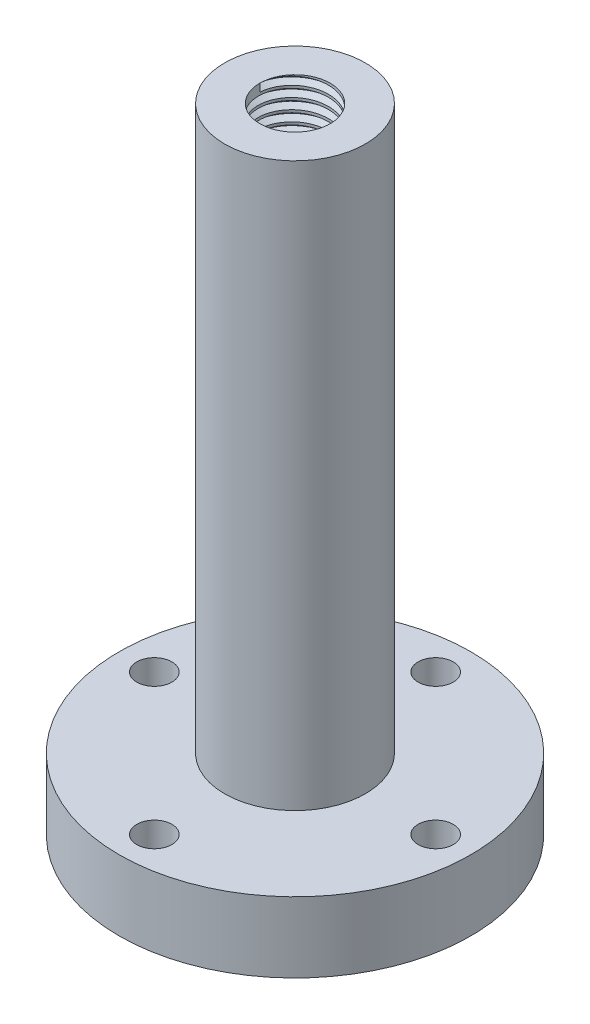
from build123d import *

# Parameters (mm, degrees)
SKETCH1_R           = 25
BOSS_EXTRUDE1_DEPTH = 10
SKETCH2_R           = 10
BOSS_EXTRUDE2_DEPTH = 80
SKETCH3_R           = 5
CUT_EXTRUDE1_DEPTH  = 97.695398029
THREAD1_PITCH       = 1.5
THREAD1_HEIGHT      = 10
THREAD1_RADIUS      = 5
THREAD1_START_ANGLE = -90
SKETCH6_R           = 2.5
CUT_EXTRUDE2_DEPTH  = 97.695398122


with BuildPart() as part:
    # Sketch1 → Boss-Extrude1 (new body)
    with BuildSketch(Plane(origin=(0, 0, 0), x_dir=(1, 0, 0), z_dir=(0, 1, 0))):
        with Locations(Location((0, 0, 0), (0, 0, 270))):
            Circle(SKETCH1_R)
    extrude(amount=BOSS_EXTRUDE1_DEPTH)

    # Sketch2 → Boss-Extrude2 (add)
    with BuildSketch(Plane(origin=(0, 10, 0), x_dir=(1, 0, 0), z_dir=(0, 1, 0))):
        with Locations(Location((0, 0, 0), (0, 0, 270))):
            Circle(SKETCH2_R)
    extrude(amount=BOSS_EXTRUDE2_DEPTH)

    # Sketch3 → Cut-Extrude1 (cut, through all)
    with BuildSketch(Plane(origin=(0, 90, 0), x_dir=(1, 0, 0), z_dir=(0, 1, 0))):
        with Locations(Location((0, 0, 0), (0, 0, 270))):
            Circle(SKETCH3_R)
    extrude(amount=-CUT_EXTRUDE1_DEPTH, mode=Mode.SUBTRACT)

    # Thread1: sweep along a helix
    with BuildLine() as thread1_path:
        add(Helix(THREAD1_PITCH, THREAD1_HEIGHT, THREAD1_RADIUS, center=(0, 90, 0), direction=(0, -1, 0), mode=Mode.PRIVATE).rotate(Axis((0, 90, 0), (0, -1, 0)), THREAD1_START_ANGLE))
    # Thread Profile1 → Thread1 (sweep, cut)
    with BuildSketch(Plane(origin=(-5, 90, 0), x_dir=(-1, 0, 0), z_dir=(0, 0, 1))):
        Polygon((0, 0), (0.811898813, 0.468749998), (0.811898813, 0.656249998), (0, 1.124999996), align=None)
    sweep(path=thread1_path.line, is_frenet=True, mode=Mode.SUBTRACT)

    # Sketch6 → Cut-Extrude2 (cut, through all)
    with BuildSketch(Plane.XZ):
        with Locations(Location((0, 20, 0), (0, 0, 270))):
            Circle(SKETCH6_R)
        with Locations(Location((20, 0, 0), (0, 0, 270))):
            Circle(SKETCH6_R)
        with Locations(Location((0, -20, 0), (0, 0, 270))):
            Circle(SKETCH6_R)
        with Locations(Location((-20, 0, 0), (0, 0, 270))):
            Circle(SKETCH6_R)
    extrude(amount=-CUT_EXTRUDE2_DEPTH, mode=Mode.SUBTRACT)


solid = part.part
